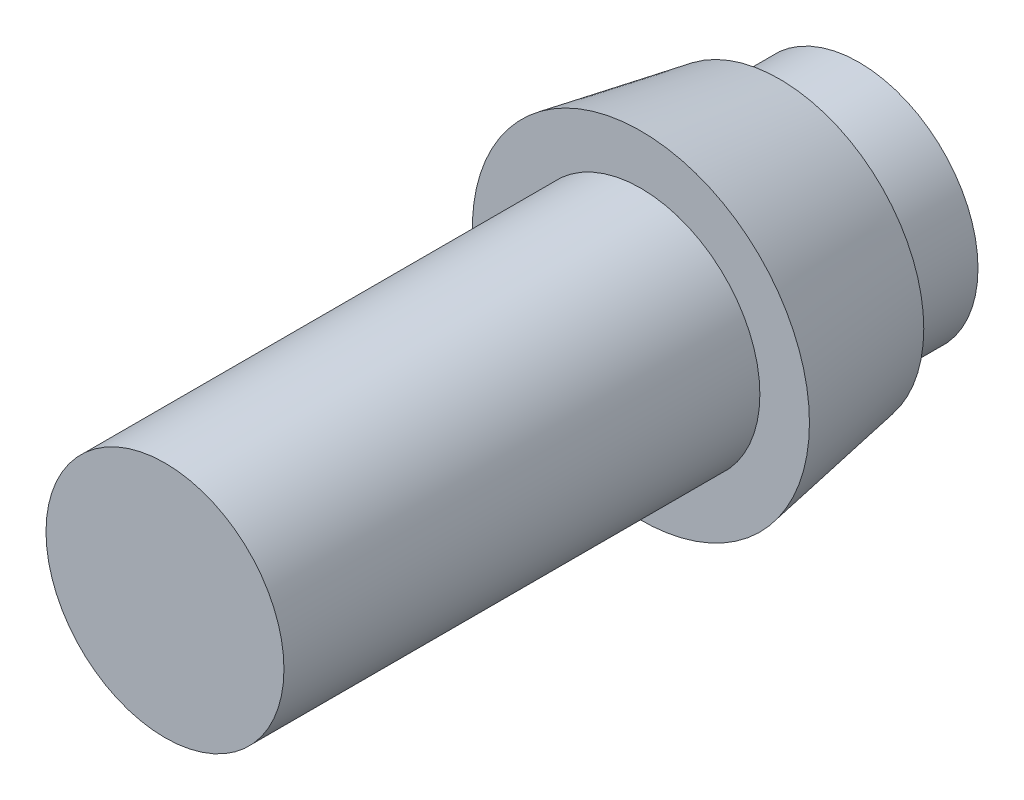
from build123d import *

# Parameters (mm, degrees)
SKETCH1_R           = 6
BOSS_EXTRUDE1_DEPTH = 24
SKETCH2_R           = 8.5
BOSS_EXTRUDE2_DEPTH = 7
BOSS_EXTRUDE2_TAPER = 10
BOSS_EXTRUDE3_START = -7
SKETCH3_R           = 6
BOSS_EXTRUDE3_DEPTH = 4


with BuildPart() as part:
    # Sketch1 → Boss-Extrude1 (new body)
    with BuildSketch(Plane.XY):
        Circle(SKETCH1_R)
    extrude(amount=BOSS_EXTRUDE1_DEPTH)

    # Sketch2 → Boss-Extrude2 (add)
    with BuildSketch(Plane.XY):
        Circle(SKETCH2_R)
    extrude(amount=-BOSS_EXTRUDE2_DEPTH, taper=BOSS_EXTRUDE2_TAPER)

    # Sketch3 → Boss-Extrude3 (add)
    with BuildSketch(Plane.XY.offset(BOSS_EXTRUDE3_START)):
        Circle(SKETCH3_R)
    extrude(amount=-BOSS_EXTRUDE3_DEPTH)


solid = part.part
